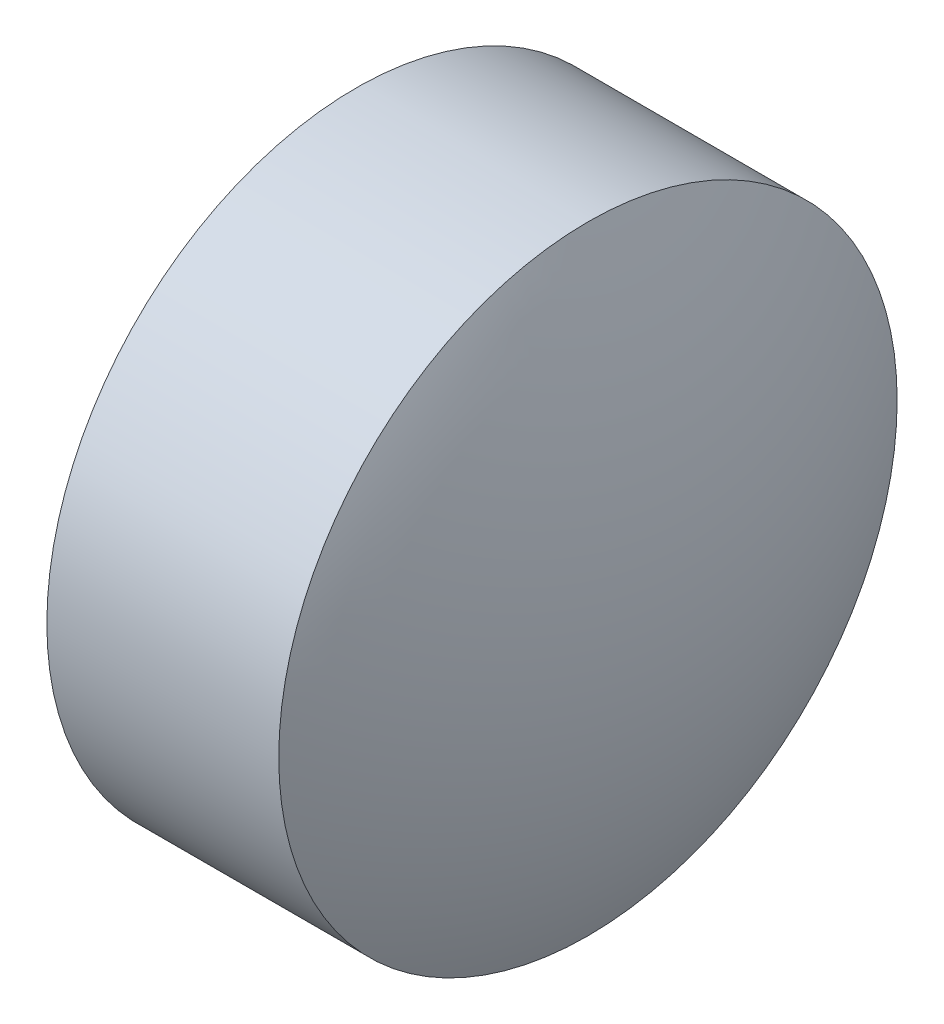
from build123d import *


with BuildPart() as part:
    # 草图1 → 旋转1 (revolve)
    with BuildSketch(Plane.XY):
        with BuildLine():
            Line((416.98491772, 167.108864965), (416.98491772, 169.108864965))
            Line((416.98491772, 169.108864965), (418.48491772, 169.108864965))
            ThreePointArc((418.48491772, 169.108864965), (418.82843579, 168.134974121), (418.94491772, 167.108864965))
            Line((418.94491772, 167.108864965), (416.98491772, 167.108864965))
        make_face()
    revolve(axis=Axis((416.556811026, 167.108864965, 0), (1, 0, 0)))


solid = part.part
